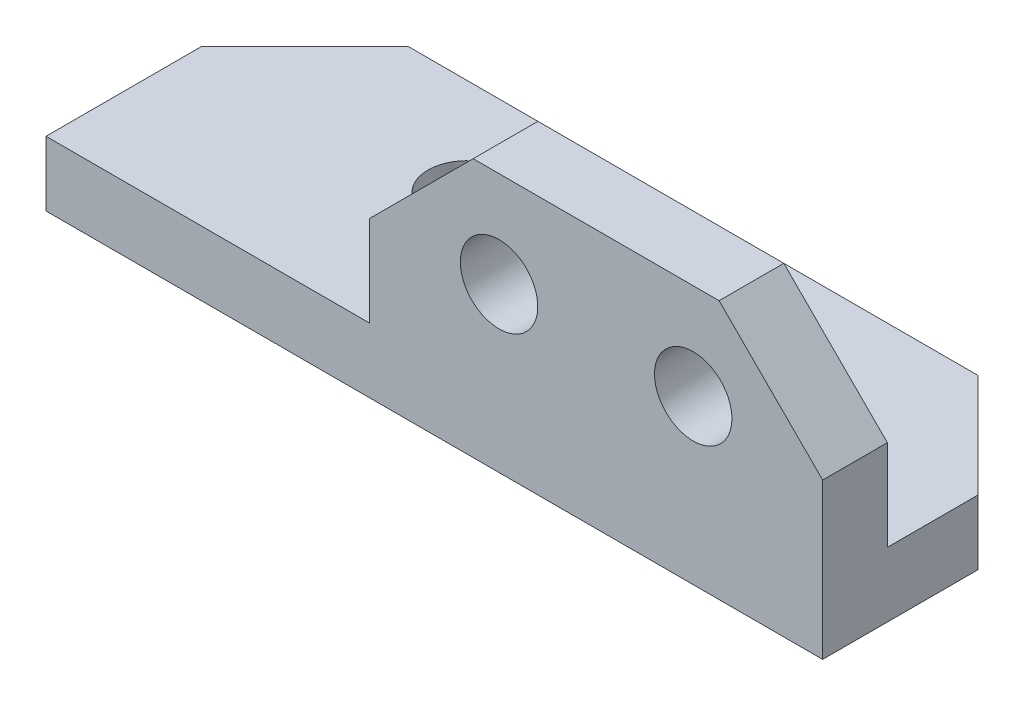
from build123d import *

# Parameters (mm, degrees)
EXTRUDE1_DEPTH                      = 19.05
EXTRUDE1_DEPTH_BACK                 = 19.05
F_6_CLEARANCE_HOLE1_D               = 3.7973
F_6_CLEARANCE_HOLE1_DEPTH           = 6.35
F_6_CLEARANCE_HOLE1_TIP             = 1.140824014
F_6_CLEARANCE_HOLE1_ON_FACE_2_D     = 3.7973
F_6_CLEARANCE_HOLE1_ON_FACE_2_DEPTH = 6.35
F_6_CLEARANCE_HOLE1_ON_FACE_2_TIP   = 1.140824014
SKETCH3_W                           = 15.875
SKETCH3_H                           = 9.525
CUT_EXTRUDE1_DEPTH                  = 4.175
CHAMFER1_SIZE                       = 5.08


with BuildPart() as part:
    # Sketch1 → Extrude1 (new body, two sides)
    with BuildSketch(Plane(origin=(0, 0, 0), x_dir=(0, 0, -1), z_dir=(1, 0, 0))) as extrude1_sk:
        Polygon((-3.175, 9.525), (-3.175, -3.175), (9.525, -3.175), (9.525, 0), (0, 0), (0, 9.525), align=None)
    extrude(amount=EXTRUDE1_DEPTH)
    extrude(extrude1_sk.sketch, amount=-EXTRUDE1_DEPTH_BACK)

    # 6 Clearance Hole1
    with Locations(Plane(origin=(6.35, 0, -4.7625), x_dir=(0, 0, 1), z_dir=(0, 1, 0))):
        with Locations((0, 0), (0, -12.7)):
            Hole(F_6_CLEARANCE_HOLE1_D / 2, depth=F_6_CLEARANCE_HOLE1_DEPTH)
            with Locations((0, 0, -(F_6_CLEARANCE_HOLE1_DEPTH + F_6_CLEARANCE_HOLE1_TIP / 2))):  # 118° drill point
                Cone(0, F_6_CLEARANCE_HOLE1_D / 2, F_6_CLEARANCE_HOLE1_TIP, mode=Mode.SUBTRACT)

    # 6 Clearance Hole1 on face 2
    with Locations(Plane(origin=(3.175, 4.826, 0), x_dir=(-1, 0, 0), z_dir=(0, 0, -1))):
        with Locations((0, 0), (-9.525, 0)):
            Hole(F_6_CLEARANCE_HOLE1_ON_FACE_2_D / 2, depth=F_6_CLEARANCE_HOLE1_ON_FACE_2_DEPTH)
            with Locations((0, 0, -(F_6_CLEARANCE_HOLE1_ON_FACE_2_DEPTH + F_6_CLEARANCE_HOLE1_ON_FACE_2_TIP / 2))):  # 118° drill point
                Cone(0, F_6_CLEARANCE_HOLE1_ON_FACE_2_D / 2, F_6_CLEARANCE_HOLE1_ON_FACE_2_TIP, mode=Mode.SUBTRACT)

    # Sketch3 → Cut-Extrude1 (cut, through all)
    with BuildSketch(Plane(origin=(0, 0, 0), x_dir=(-1, 0, 0), z_dir=(0, 0, -1))):
        with Locations((11.1125, 4.7625)):
            Rectangle(SKETCH3_W, SKETCH3_H)
    extrude(amount=-CUT_EXTRUDE1_DEPTH, mode=Mode.SUBTRACT)

    # Chamfer1
    chamfer1_edges = [part.edges().sort_by_distance(p)[0] for p in [
        (19.05, -1.5875, -9.525),
        (-19.05, -1.5875, -9.525),
        (19.05, 9.525, 1.5875),
        (-3.175, 9.525, 1.5875),
    ]]
    chamfer(chamfer1_edges, length=CHAMFER1_SIZE)


solid = part.part
